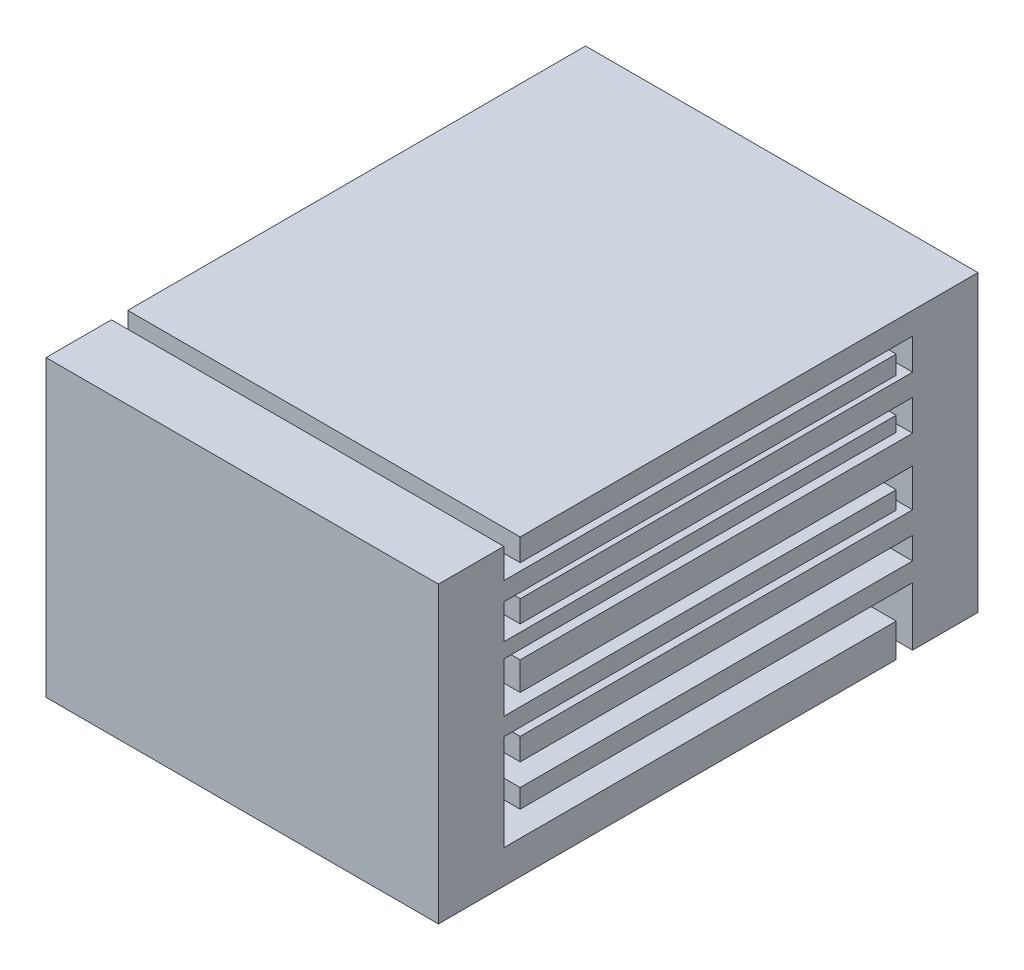
from build123d import *

# Parameters (mm, degrees)
SKETCH1_W           = 120
SKETCH1_H           = 90
BOSS_EXTRUDE1_DEPTH = 20
SKETCH2_W           = 120
SKETCH2_H           = 6.825131856
SKETCH2_H_2         = 6.669593715
SKETCH2_H_3         = 8.654042108
SKETCH2_H_4         = 6.760829407
BOSS_EXTRUDE2_DEPTH = 120
BOSS_EXTRUDE3_START = 5
SKETCH3_W           = 120
SKETCH3_H           = 90
BOSS_EXTRUDE3_DEPTH = 20
SKETCH4_W           = 120
SKETCH4_H           = 10.204938942
SKETCH4_H_2         = 5.422041007
SKETCH4_H_3         = 4.532546326
SKETCH4_H_4         = 5.616460423
BOSS_EXTRUDE4_DEPTH = 120
SKETCH6_W           = 120
SKETCH6_H           = 5.739167773
BOSS_EXTRUDE5_DEPTH = 120


with BuildPart() as part:
    # Sketch1 → Boss-Extrude1 (new body)
    with BuildSketch(Plane.XY):
        Rectangle(SKETCH1_W, SKETCH1_H)
    extrude(amount=BOSS_EXTRUDE1_DEPTH)

    # Sketch2 → Boss-Extrude2 (add)
    with BuildSketch(Plane.XY.offset(20)):
        with Locations((0, 41.587434072)):
            Rectangle(SKETCH2_W, SKETCH2_H)
        with Locations((0, 25.292270515)):
            Rectangle(SKETCH2_W, SKETCH2_H_2)
        with Locations((0, 8.127218066)):
            Rectangle(SKETCH2_W, SKETCH2_H_3)
        with Locations((0, -11.199496108)):
            Rectangle(SKETCH2_W, SKETCH2_H_4)
    extrude(amount=BOSS_EXTRUDE2_DEPTH)

    # Sketch6 → Boss-Extrude5 (add)
    with BuildSketch(Plane.XY.offset(20)):
        with Locations((0, -24.230856336)):
            Rectangle(SKETCH6_W, SKETCH6_H)
    extrude(amount=BOSS_EXTRUDE5_DEPTH)


with BuildPart() as body_2:
    # Sketch3 → Boss-Extrude3 (new body)
    with BuildSketch(Plane.XY.offset(140).offset(BOSS_EXTRUDE3_START)):
        Rectangle(SKETCH3_W, SKETCH3_H)
    extrude(amount=BOSS_EXTRUDE3_DEPTH)

    # Sketch4 → Boss-Extrude4 (add)
    with BuildSketch(Plane(origin=(0, 0, 145), x_dir=(-1, 0, 0), z_dir=(0, 0, -1))):
        with Locations((0, -39.897530529)):
            Rectangle(SKETCH4_W, SKETCH4_H)
        with Locations((0, -2.711020504)):
            Rectangle(SKETCH4_W, SKETCH4_H_2)
        with Locations((0, 17.465860455)):
            Rectangle(SKETCH4_W, SKETCH4_H_3)
        with Locations((0, 33.117464461)):
            Rectangle(SKETCH4_W, SKETCH4_H_4)
    extrude(amount=BOSS_EXTRUDE4_DEPTH)


solid = Compound([part.part, body_2.part])
